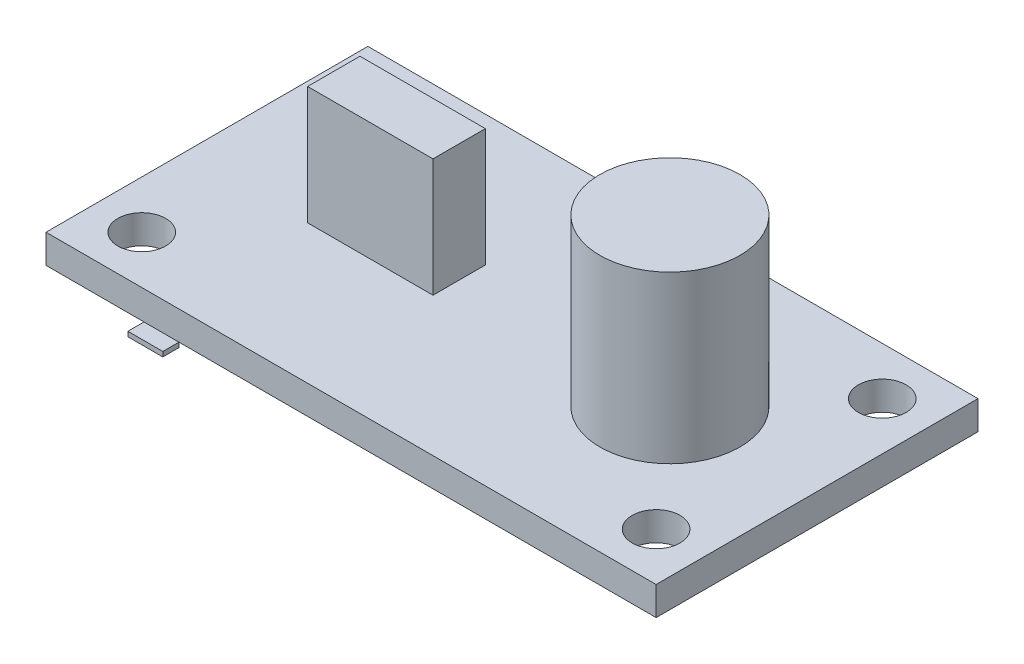
from build123d import *

# Parameters (mm, degrees)
SKETCH1_W           = 38.23
SKETCH1_H           = 20.17
SKETCH1_R           = 1.5
BOSS_EXTRUDE1_DEPTH = 1.8
SKETCH5_W           = 2.189263985
SKETCH5_H           = 1.01
BOSS_EXTRUDE2_DEPTH = 0.3
SKETCH6_R           = 4.390112711
BOSS_EXTRUDE3_DEPTH = 12.2
SKETCH7_W           = 7.855644305
SKETCH7_H           = 3.28037894
BOSS_EXTRUDE4_DEPTH = 9.2


with BuildPart() as part:
    # Sketch1 → Boss-Extrude1 (new body)
    with BuildSketch(Plane(origin=(0, 0, 0), x_dir=(1, 0, 0), z_dir=(0, 1, 0))):
        with Locations((-0.124663043, 5.747206522)):
            Rectangle(SKETCH1_W, SKETCH1_H)
        with Locations((-16.239663043, 12.832206522)):
            Circle(SKETCH1_R, mode=Mode.SUBTRACT)
        with Locations((15.990336957, 12.832206522)):
            Circle(SKETCH1_R, mode=Mode.SUBTRACT)
        with Locations((15.990336957, -1.337793478)):
            Circle(SKETCH1_R, mode=Mode.SUBTRACT)
        with Locations((-16.239663043, -1.337793478)):
            Circle(SKETCH1_R, mode=Mode.SUBTRACT)
    extrude(amount=-BOSS_EXTRUDE1_DEPTH)

    # Sketch6 → Boss-Extrude3 (add)
    with BuildSketch(Plane(origin=(0, -1.8, 0), x_dir=(-1, 0, 0), z_dir=(0, -1, 0))):
        with Locations((-9.77042738, 5.747206522)):
            Circle(SKETCH6_R)
    extrude(amount=-BOSS_EXTRUDE3_DEPTH)

    # Sketch7 → Boss-Extrude4 (add)
    with BuildSketch(Plane(origin=(0, -1.8, 0), x_dir=(-1, 0, 0), z_dir=(0, -1, 0))):
        with Locations((7.624213583, 6.008347656)):
            Rectangle(SKETCH7_W, SKETCH7_H)
    extrude(amount=-BOSS_EXTRUDE4_DEPTH)


with BuildPart() as body_2:
    # Sketch5 → Boss-Extrude2 (new body)
    with BuildSketch(Plane.XZ.offset(1.8)):
        with Locations((-12.004217964, 4.842793478)):
            Rectangle(SKETCH5_W, SKETCH5_H)
    extrude(amount=BOSS_EXTRUDE2_DEPTH)


solid = Compound([part.part, body_2.part])
